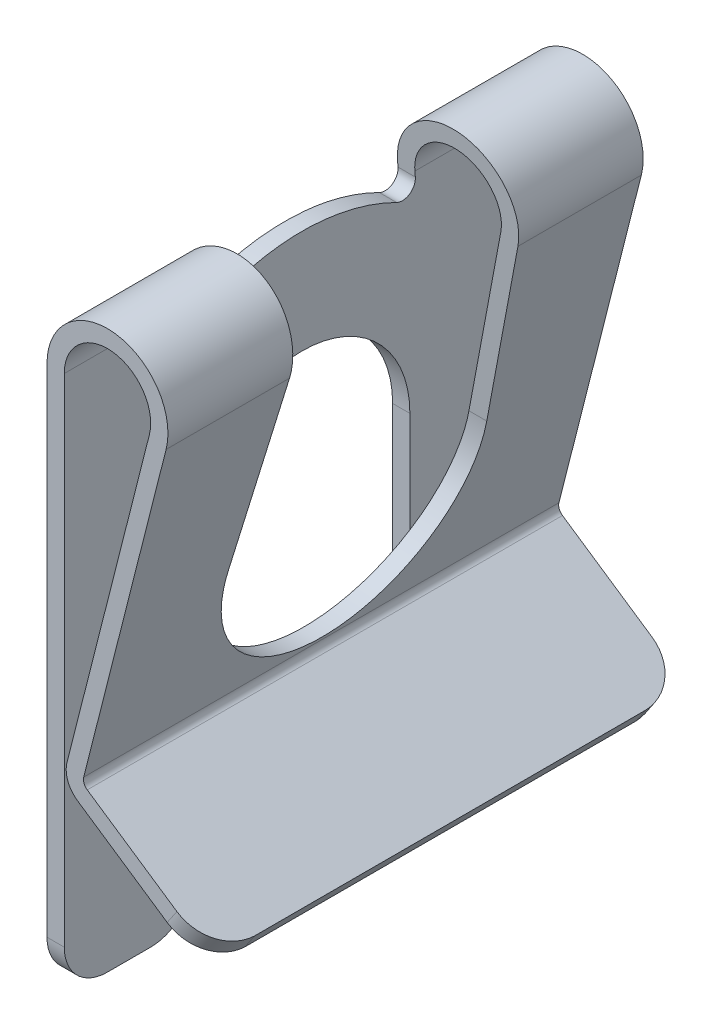
from build123d import *

# Parameters (mm, degrees)
BOSS_EXTRUDE1_DEPTH      = 5.5
BOSS_EXTRUDE1_DEPTH_BACK = 5.5
CUT_EXTRUDE1_DEPTH       = 0.4
CUT_EXTRUDE2_DEPTH       = 3.8
CUT_EXTRUDE3_DEPTH       = 3.8
CUT_EXTRUDE4_DEPTH       = 0.4
CUT_EXTRUDE5_DEPTH       = 0.4
CUT_EXTRUDE6_DEPTH       = 0.4
CUT_EXTRUDE7_DEPTH       = 0.4
CUT_EXTRUDE8_DEPTH       = 0.8
CUT_EXTRUDE8_DEPTH_BACK  = 0.8


with BuildPart() as part:
    # Sketch1 → Boss-Extrude1 (new, two sides: drawn at the far end of the back side and taken through both)
    with BuildSketch(Plane.XY.offset(-BOSS_EXTRUDE1_DEPTH_BACK)):
        with BuildLine():
            Line((0, 4.8), (0, -7.7))
            Line((0, -7.7), (0.4, -7.7))
            Line((0.4, -7.7), (0.4, 4.8))
            ThreePointArc((0.4, 4.8), (1.523848484, 5.79230114), (2.369323106, 4.554210017))
            Line((2.369323106, 4.554210017), (0.462124676, -2.967217351))
            ThreePointArc((0.462124676, -2.967217351), (0.483070792, -3.328406344), (0.707868785, -3.611888427))
            Line((0.707868785, -3.611888427), (3.611166589, -5.573025933))
            Line((3.611166589, -5.573025933), (3.835066425, -5.241561209))
            Line((3.835066425, -5.241561209), (0.931768621, -3.280423703))
            ThreePointArc((0.931768621, -3.280423703), (0.856835957, -3.185929675), (0.849853918, -3.065533344))
            Line((0.849853918, -3.065533344), (2.757052349, 4.455894023))
            ThreePointArc((2.757052349, 4.455894023), (1.573387877, 6.189221596), (0, 4.8))
        make_face()
    extrude(amount=BOSS_EXTRUDE1_DEPTH + BOSS_EXTRUDE1_DEPTH_BACK)

    # Sketch2 → Cut-Extrude1 (cut)
    with BuildSketch(Plane(origin=(0, 0, 0), x_dir=(0, 0, -1), z_dir=(1, 0, 0))):
        with BuildLine():
            Line((-2.5, 0), (-2.5, -7.7))
            Line((-2.5, -7.7), (2.5, -7.7))
            Line((2.5, -7.7), (2.5, 0))
            ThreePointArc((2.5, 0), (0, 2.5), (-2.5, 0))
        make_face()
    extrude(amount=CUT_EXTRUDE1_DEPTH, mode=Mode.SUBTRACT)

    # Sketch3 → Cut-Extrude2 (cut)
    with BuildSketch(Plane(origin=(0.4, 0, 0), x_dir=(0, 0, -1), z_dir=(1, 0, 0))):
        with BuildLine():
            Line((2.989896199, 0.246009597), (2.5, 6.2))
            Line((2.5, 6.2), (-2.5, 6.2))
            Line((-2.5, 6.2), (-2.989896199, 0.246009597))
            ThreePointArc((-2.989896199, 0.246009597), (0, -3), (2.989896199, 0.246009597))
        make_face()
    extrude(amount=CUT_EXTRUDE2_DEPTH, mode=Mode.SUBTRACT)

    # Sketch4 → Cut-Extrude3 (cut)
    with BuildSketch(Plane(origin=(0.4, 0, 0), x_dir=(0, 0, -1), z_dir=(1, 0, 0))):
        with BuildLine():
            Line((2.62546601, 4.675139381), (2.5, 6.2))
            Line((2.5, 6.2), (-2.5, 6.2))
            Line((-2.5, 6.2), (-2.62546601, 4.675139381))
            ThreePointArc((-2.62546601, 4.675139381), (-2.494509309, 4.402012893), (-2.192256609, 4.382238122))
            ThreePointArc((-2.192256609, 4.382238122), (-6e-09, 4.9), (2.192256599, 4.382238127))
            ThreePointArc((2.192256599, 4.382238127), (2.494509304, 4.402012889), (2.62546601, 4.675139381))
        make_face()
    extrude(amount=-CUT_EXTRUDE3_DEPTH, mode=Mode.SUBTRACT)

    # Sketch5 → Cut-Extrude4 (cut)
    with BuildSketch(Plane(origin=(0, 0, 0), x_dir=(0, 0, -1), z_dir=(1, 0, 0))):
        with BuildLine():
            Line((-5.5, -7.7), (-4.5, -7.7))
            ThreePointArc((-4.5, -7.7), (-5.207106781, -7.407106781), (-5.5, -6.7))
            Line((-5.5, -6.7), (-5.5, -7.7))
        make_face()
    extrude(amount=CUT_EXTRUDE4_DEPTH, mode=Mode.SUBTRACT)

    # Sketch6 → Cut-Extrude5 (cut)
    with BuildSketch(Plane(origin=(0, 0, 0), x_dir=(0, 0, -1), z_dir=(1, 0, 0))):
        with BuildLine():
            Line((4.5, -7.7), (5.5, -7.7))
            Line((5.5, -7.7), (5.5, -6.7))
            ThreePointArc((5.5, -6.7), (5.207106781, -7.407106781), (4.5, -7.7))
        make_face()
    extrude(amount=CUT_EXTRUDE5_DEPTH, mode=Mode.SUBTRACT)

    # Sketch7 → Cut-Extrude6 (cut)
    with BuildSketch(Plane(origin=(0, 0, 0), x_dir=(0, 0, -1), z_dir=(1, 0, 0))):
        with BuildLine():
            Line((2.5, -7.7), (3.5, -7.7))
            ThreePointArc((3.5, -7.7), (2.792893219, -7.407106781), (2.5, -6.7))
            Line((2.5, -6.7), (2.5, -7.7))
        make_face()
    extrude(amount=CUT_EXTRUDE6_DEPTH, mode=Mode.SUBTRACT)

    # Sketch8 → Cut-Extrude7 (cut)
    with BuildSketch(Plane(origin=(0, 0, 0), x_dir=(0, 0, -1), z_dir=(1, 0, 0))):
        with BuildLine():
            Line((-3.5, -7.7), (-2.5, -7.7))
            Line((-2.5, -7.7), (-2.5, -6.7))
            ThreePointArc((-2.5, -6.7), (-2.792893219, -7.407106781), (-3.5, -7.7))
        make_face()
    extrude(amount=CUT_EXTRUDE7_DEPTH, mode=Mode.SUBTRACT)

    # Sketch9 → Cut-Extrude8 (cut, two sides: drawn at the far end of the back side and taken through both)
    with BuildSketch(Plane(origin=(-1.229660553, -1.820408193, 0), x_dir=(0.8286618104657849, -0.5597495903308619, 0), z_dir=(0.5597495903308619, 0.8286618104657849, 0)).offset(-CUT_EXTRUDE8_DEPTH_BACK)):
        with BuildLine():
            Line((6.112336896, 4.5), (6.112336896, -4.5))
            ThreePointArc((6.112336896, -4.5), (5.819443678, -5.207106781), (5.112336896, -5.5))
            Line((5.112336896, -5.5), (5.112336896, -6.5))
            Line((5.112336896, -6.5), (7.112336896, -6.5))
            Line((7.112336896, -6.5), (7.112336896, 6.5))
            Line((7.112336896, 6.5), (5.112336896, 6.5))
            Line((5.112336896, 6.5), (5.112336896, 5.5))
            ThreePointArc((5.112336896, 5.5), (5.819443678, 5.207106781), (6.112336896, 4.5))
        make_face()
    extrude(amount=CUT_EXTRUDE8_DEPTH + CUT_EXTRUDE8_DEPTH_BACK, mode=Mode.SUBTRACT)


solid = part.part
